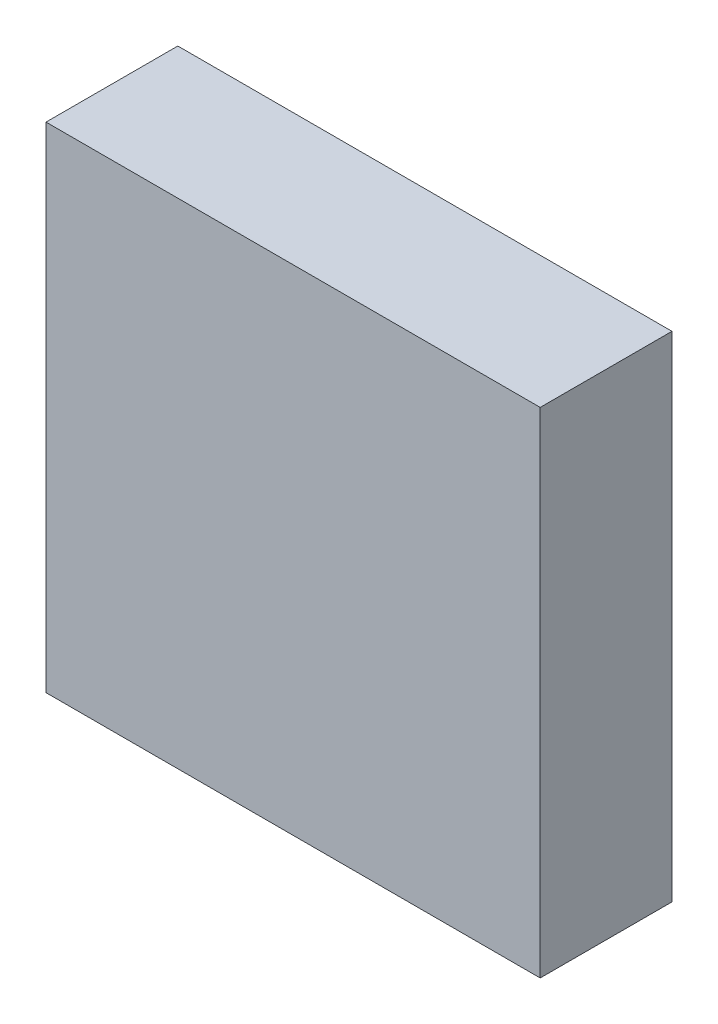
from build123d import *

# Parameters (mm, degrees)
ESBO_O1_W                = 150
ESBO_O1_H                = 150
RESSALTO_EXTRUS_O1_DEPTH = 40


with BuildPart() as part:
    # Esboço1 → Ressalto-extrusão1 (new body)
    with BuildSketch(Plane.XY):
        with Locations((75, 75)):
            Rectangle(ESBO_O1_W, ESBO_O1_H)
    extrude(amount=RESSALTO_EXTRUS_O1_DEPTH)


solid = part.part
